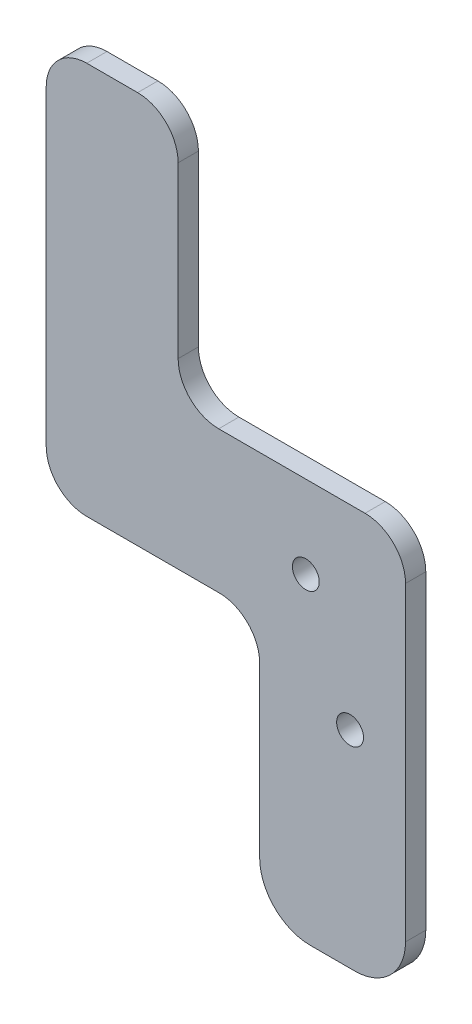
from build123d import *

# Parameters (mm, degrees)
SKETCH1_W            = 28.802861634
SKETCH1_H            = 131.078546172
BOSS_EXTRUDE1_DEPTH  = 4
M5_CLEARANCE_HOLE1_D = 5.3
FILLET1_R            = 10
M5_CLEARANCE_HOLE2_D = 5.3
BOSS_EXTRUDE2_DEPTH  = 4
SKETCH8_W            = 47.461989215
SKETCH8_H            = 54.002733852
CUT_EXTRUDE1_DEPTH   = 14.4
FILLET2_R            = 8


with BuildPart() as part:
    # Sketch1 → Boss-Extrude1 (new body)
    with BuildSketch(Plane.XY):
        with Locations((-48.87450938, -319.394379884)):
            Rectangle(SKETCH1_W, SKETCH1_H)
    extrude(amount=BOSS_EXTRUDE1_DEPTH)

    # M5 Clearance Hole1 (through all)
    with Locations(Plane.XY.offset(4)):
        with Locations((-54.16270611, -321.915681156), (-54.16270611, -293.415681156)):
            Hole(M5_CLEARANCE_HOLE1_D / 2)

    # Fillet1
    fillet1_edges = [part.edges().sort_by_distance(p)[0] for p in [
        (-63.275940197, -253.855106798, 2),
        (-34.473078563, -253.855106798, 2),
        (-34.473078563, -384.93365297, 2),
        (-63.275940197, -384.93365297, 2),
    ]]
    fillet(fillet1_edges, radius=FILLET1_R)

    # M5 Clearance Hole2 (through all)
    with Locations(Plane(origin=(0, 0, 0), x_dir=(-1, 0, 0), z_dir=(0, 0, -1))):
        with Locations((45.426427008, -344.165502047)):
            Hole(M5_CLEARANCE_HOLE2_D / 2)

    # Sketch7 → Boss-Extrude2 (add)
    with BuildSketch(Plane.XY.offset(4)):
        Polygon((-63.275940197, -333.655681156), (-105.425150803, -333.655681156), (-105.425150803, -256.153534459), (-79.372706111, -256.153534459), (-79.372706111, -305.639740344), (-63.275940197, -305.639740344), align=None)
    extrude(amount=-BOSS_EXTRUDE2_DEPTH)

    # Sketch8 → Cut-Extrude1 (cut)
    with BuildSketch(Plane(origin=(0, 0, 0), x_dir=(-1, 0, 0), z_dir=(0, 0, -1))):
        with Locations((47.593328547, -278.638373418)):
            Rectangle(SKETCH8_W, SKETCH8_H)
    extrude(amount=-CUT_EXTRUDE1_DEPTH, mode=Mode.SUBTRACT)

    # Fillet2
    fillet2_edges = [part.edges().sort_by_distance(p)[0] for p in [
        (-63.275940197, -333.655681156, 2),
        (-105.425150803, -333.655681156, 2),
        (-105.425150803, -256.153534459, 2),
        (-79.372706111, -256.153534459, 2),
        (-79.372706111, -305.639740344, 2),
        (-34.473078563, -305.639740344, 2),
    ]]
    fillet(fillet2_edges, radius=FILLET2_R)


solid = part.part
